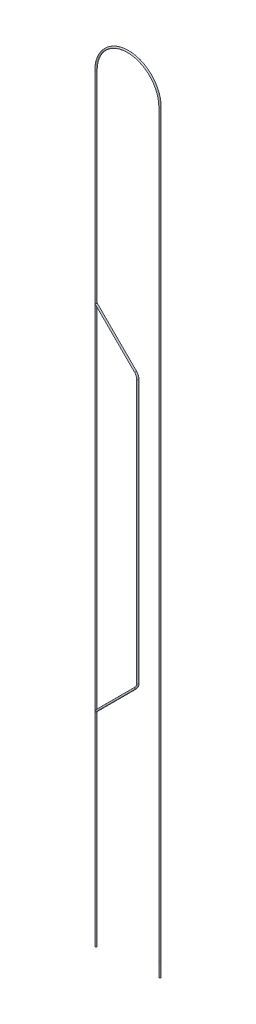
from build123d import *

# Parameters (mm, degrees)
SWEEP_THIN1_PROFILE_R   = 15
SWEEP_THIN1_PROFILE_R_2 = 13
SWEEP_THIN2_PROFILE_R   = 15
SWEEP_THIN2_PROFILE_R_2 = 13


with BuildPart() as part:
    # Sweep-Thin1: sweep along a curve in space
    with BuildLine() as sweep_thin1_path:
        Line((-22746.078763, -1710.051852, 40492.963805), (-22746.078763, -2059.450458, 40492.963805))
        Line((-22746.078763, 11679.11051, 40492.963805), (-22746.078763, -1710.051852, 40492.963805))
        ThreePointArc((-21588.078763, 11679.11051, 40492.963805), (-22167.078763, 12258.11051, 40492.963805), (-22746.078763, 11679.11051, 40492.963805))
        Line((-21588.078763, -1707.035791, 40492.963805), (-21588.078763, 11679.11051, 40492.963805))
        Line((-21588.078763, -1707.035791, 40492.963805), (-21588.078763, -1963.807037, 40492.963805))
    # Sweep-Thin1 profile (on start of the path) → Sweep-Thin1 (sweep)
    with BuildSketch(Plane(origin=(-21588.078763, -1963.807037, 40492.963805), x_dir=(0, 2.6097770154123424e-11, 1.0), z_dir=(-7.367448686288915e-13, 1.0, -2.6097770154123424e-11))):
        Circle(SWEEP_THIN1_PROFILE_R)
        Circle(SWEEP_THIN1_PROFILE_R_2, mode=Mode.SUBTRACT)
    sweep(path=sweep_thin1_path.line)

    # Sweep-Thin2: sweep along a curve in space
    with BuildLine() as sweep_thin2_path:
        Line((-22746.078763, 8023.025683, 40492.963805), (-22029.381975, 7306.328895, 40492.963805))
        ThreePointArc((-22029.381975, 7306.328895, 40492.963805), (-21999.703219, 7261.911498, 40492.963805), (-21989.281426, 7209.517605, 40492.963805))
        Line((-21989.281426, 7209.517605, 40492.963805), (-21989.281426, 2446.196521, 40492.963805))
        ThreePointArc((-21989.281426, 2446.196521, 40492.963805), (-21999.703219, 2393.802629, 40492.963805), (-22029.381975, 2349.385231, 40492.963805))
        Line((-22029.381975, 2349.385231, 40492.963805), (-22746.078763, 1632.688443, 40492.963805))
    # Sweep-Thin2 profile (on start of the path) → Sweep-Thin2 (sweep)
    with BuildSketch(Plane(origin=(-22746.078763, 8023.025683, 40492.963805), x_dir=(-0.7071067811865493, -0.7071067811865457, 0), z_dir=(0.7071067811865457, -0.7071067811865493, 0))):
        Circle(SWEEP_THIN2_PROFILE_R)
        Circle(SWEEP_THIN2_PROFILE_R_2, mode=Mode.SUBTRACT)
    sweep(path=sweep_thin2_path.line)


solid = part.part
